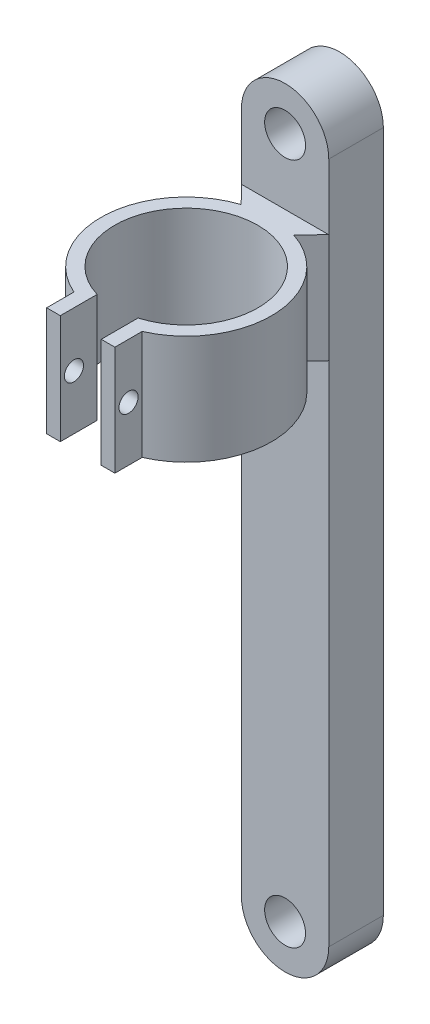
from build123d import *

# Parameters (mm, degrees)
SKETCH1_R           = 1.905
BOSS_EXTRUDE1_DEPTH = 5.08
BOSS_EXTRUDE2_START = 10.16
BOSS_EXTRUDE2_DEPTH = 10.16
SKETCH3_R           = 0.889
CUT_EXTRUDE1_DEPTH  = 12.1125


with BuildPart() as part:
    # Sketch1 → Boss-Extrude1 (new body)
    with BuildSketch(Plane(origin=(-856.488519717, 635.703940982, 371.824950285), x_dir=(1, 0, 0), z_dir=(0, 0, 1))):
        with BuildLine():
            Line((4.064, 31.75), (4.064, -31.75))
            ThreePointArc((4.064, -31.75), (0, -35.814), (-4.064, -31.75))
            Line((-4.064, -31.75), (-4.064, 31.75))
            ThreePointArc((-4.064, 31.75), (0, 35.814), (4.064, 31.75))
        make_face()
        with Locations((0, -31.75)):
            Circle(SKETCH1_R, mode=Mode.SUBTRACT)
        with Locations((0, 31.75)):
            Circle(SKETCH1_R, mode=Mode.SUBTRACT)
    extrude(amount=BOSS_EXTRUDE1_DEPTH)

    # Sketch2 → Boss-Extrude2 (add)
    with BuildSketch(Plane.XZ.offset(-671.517940982).offset(BOSS_EXTRUDE2_START)):
        with BuildLine():
            Line((-854.05175925, 378.554950285), (-852.424519717, 376.904950285))
            Line((-852.424519717, 376.904950285), (-860.552519717, 376.904950285))
            Line((-860.552519717, 376.904950285), (-858.925280183, 378.554950285))
            ThreePointArc((-858.925280183, 378.554950285), (-864.416201891, 385.714494899), (-859.663519717, 393.384000256))
            Line((-859.663519717, 393.384000256), (-859.663519717, 395.924000256))
            Line((-859.663519717, 395.924000256), (-858.393519717, 395.924000256))
            Line((-858.393519717, 395.924000256), (-858.393519717, 393.814671139))
            Line((-858.393519717, 393.814671139), (-858.393519717, 392.498725586))
            ThreePointArc((-858.393519717, 392.498725586), (-856.488519717, 379.441661341), (-854.583519717, 392.498725586))
            Line((-854.583519717, 392.498725586), (-854.583519717, 393.814671139))
            Line((-854.583519717, 393.814671139), (-854.583519717, 395.924000256))
            Line((-854.583519717, 395.924000256), (-853.313519717, 395.924000256))
            Line((-853.313519717, 395.924000256), (-853.313519717, 393.384000256))
            ThreePointArc((-853.313519717, 393.384000256), (-848.560837543, 385.714494899), (-854.05175925, 378.554950285))
        make_face()
    extrude(amount=BOSS_EXTRUDE2_DEPTH)

    # Sketch3 → Cut-Extrude1 (cut, through all)
    with BuildSketch(Plane(origin=(-853.313519717, 0, 0), x_dir=(0, 0, -1), z_dir=(1, 0, 0))):
        with Locations((-394.654000256, 656.277940982)):
            Circle(SKETCH3_R)
    extrude(amount=-CUT_EXTRUDE1_DEPTH, mode=Mode.SUBTRACT)


solid = part.part
